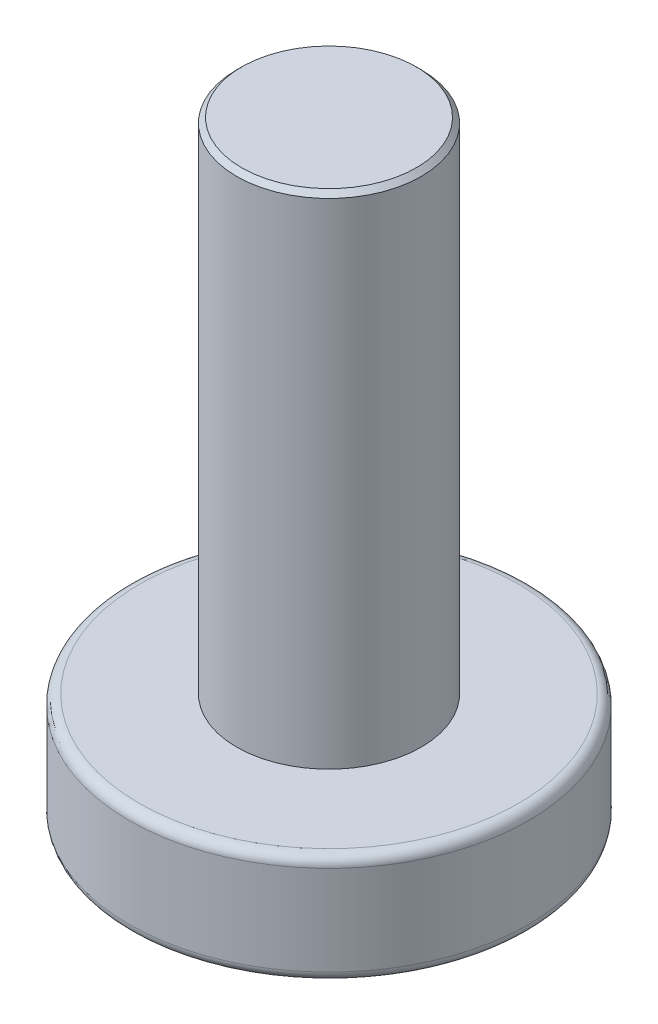
from build123d import *

# Parameters (mm, degrees)
SKETCH_1_R          = 4
EXTRUDE_1_DEPTH     = 2.2
SKETCH_2_R          = 1.85
EXTRUDE_2_DEPTH     = 10
CHAMFER_1_SIZE      = 0.1
FILLET_1_R          = 0.2
CUT_EXTRUDE_1_DEPTH = 1.5


with BuildPart() as part:
    # Эскиз1 → Бобышка-Вытянуть1 (new body)
    with BuildSketch(Plane(origin=(0, 0, 0), x_dir=(1, 0, 0), z_dir=(0, 1, 0))):
        Circle(SKETCH_1_R)
    extrude(amount=EXTRUDE_1_DEPTH)

    # Эскиз2 → Бобышка-Вытянуть2 (add)
    with BuildSketch(Plane(origin=(0, 2.2, 0), x_dir=(1, 0, 0), z_dir=(0, 1, 0))):
        Circle(SKETCH_2_R)
    extrude(amount=EXTRUDE_2_DEPTH)

    # Фаска1
    chamfer_1_edges = [part.edges().sort_by_distance(p)[0] for p in [
        (-1.85, 12.2, 0),
    ]]
    chamfer(chamfer_1_edges, length=CHAMFER_1_SIZE)

    # Скругление1
    fillet_1_edges = [part.edges().sort_by_distance(p)[0] for p in [
        (-4, 0, 0),
        (-4, 2.2, 0),
    ]]
    fillet(fillet_1_edges, radius=FILLET_1_R)

    # Эскиз3 → Вырез-Вытянуть1 (cut)
    with BuildSketch(Plane.XZ):
        Polygon((-0.5, 0.5), (-0.5, 2), (0.5, 2), (0.5, 0.5), (2, 0.5), (2, -0.5), (0.5, -0.5), (0.5, -2), (-0.5, -2), (-0.5, -0.5), (-2, -0.5), (-2, 0.5), align=None)
    extrude(amount=-CUT_EXTRUDE_1_DEPTH, mode=Mode.SUBTRACT)


solid = part.part
